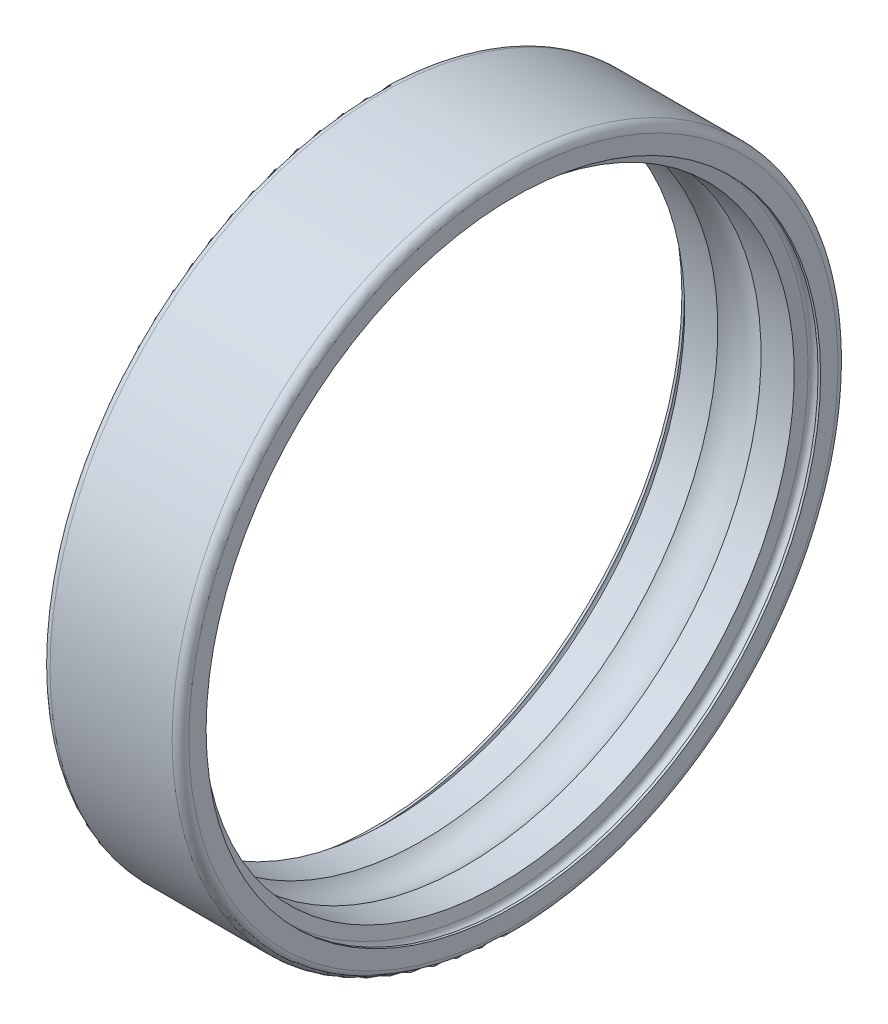
from build123d import *


with BuildPart() as part:
    # 草图1 → 旋转1 (revolve)
    with BuildSketch(Plane.XY):
        with BuildLine():
            Line((0, 11.075), (0.09, 11.075))
            ThreePointArc((0.09, 11.075), (0.27, 11.255), (0.45, 11.075))
            Line((0.45, 11.075), (0.524938967, 10.65))
            Line((0.524938967, 10.65), (1.720711703, 10.65))
            ThreePointArc((1.720711703, 10.65), (2.5, 10.9405), (3.279288297, 10.65))
            Line((3.279288297, 10.65), (4.475061033, 10.65))
            Line((4.475061033, 10.65), (4.55, 11.075))
            ThreePointArc((4.55, 11.075), (4.73, 11.255), (4.91, 11.075))
            Line((4.91, 11.075), (5, 11.075))
            Line((5, 11.075), (5, 11.7))
            ThreePointArc((5, 11.7), (4.912132034, 11.912132034), (4.7, 12))
            Line((4.7, 12), (0.3, 12))
            ThreePointArc((0.3, 12), (0.087867966, 11.912132034), (0, 11.7))
            Line((0, 11.7), (0, 11.075))
        make_face()
    revolve(axis=Axis((50, 0, 0), (-1, 0, 0)))


solid = part.part
